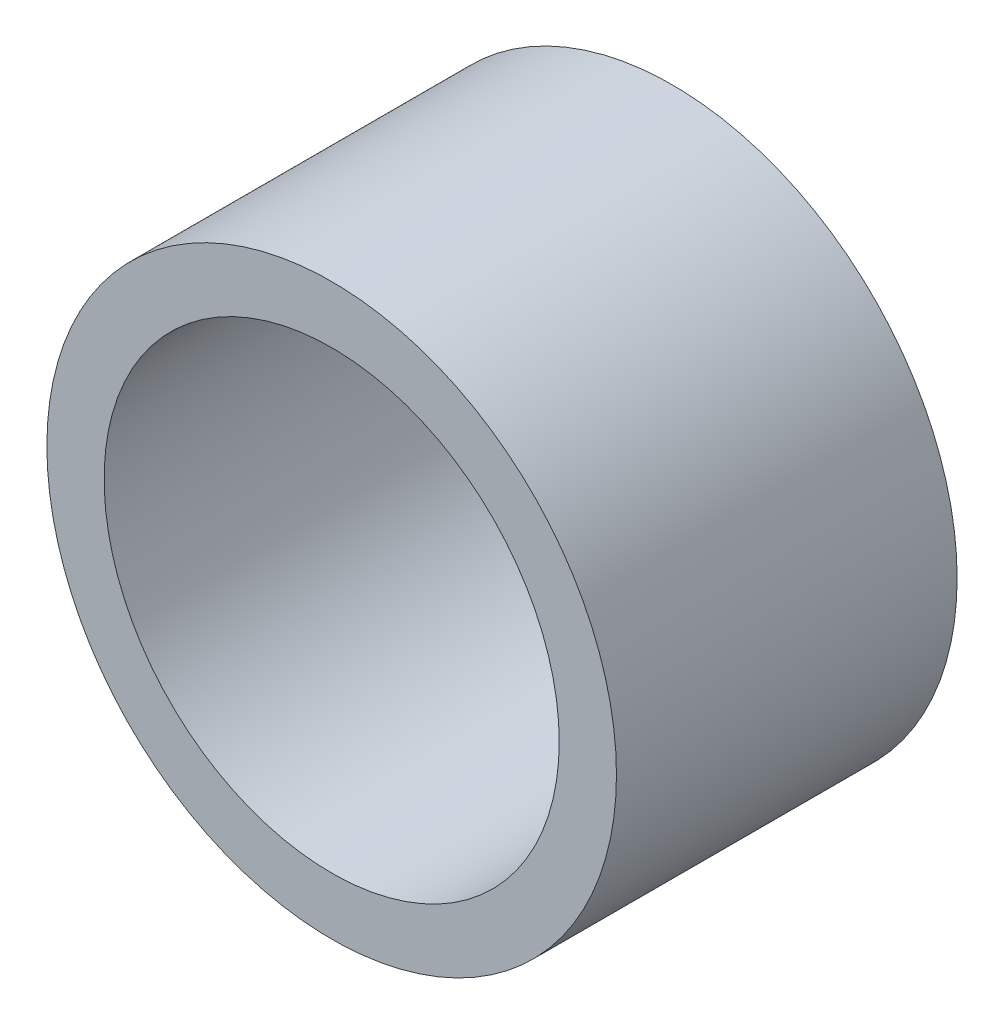
from build123d import *

# Parameters (mm, degrees)
SKETCH1_R      = 7.9629
SKETCH1_R_2    = 6.3627
EXTRUDE1_DEPTH = 4.7625


with BuildPart() as part:
    # Sketch1 → Extrude1 (new body, symmetric)
    with BuildSketch(Plane.XY):
        Circle(SKETCH1_R)
        Circle(SKETCH1_R_2, mode=Mode.SUBTRACT)
    extrude(amount=EXTRUDE1_DEPTH, both=True)


solid = part.part
